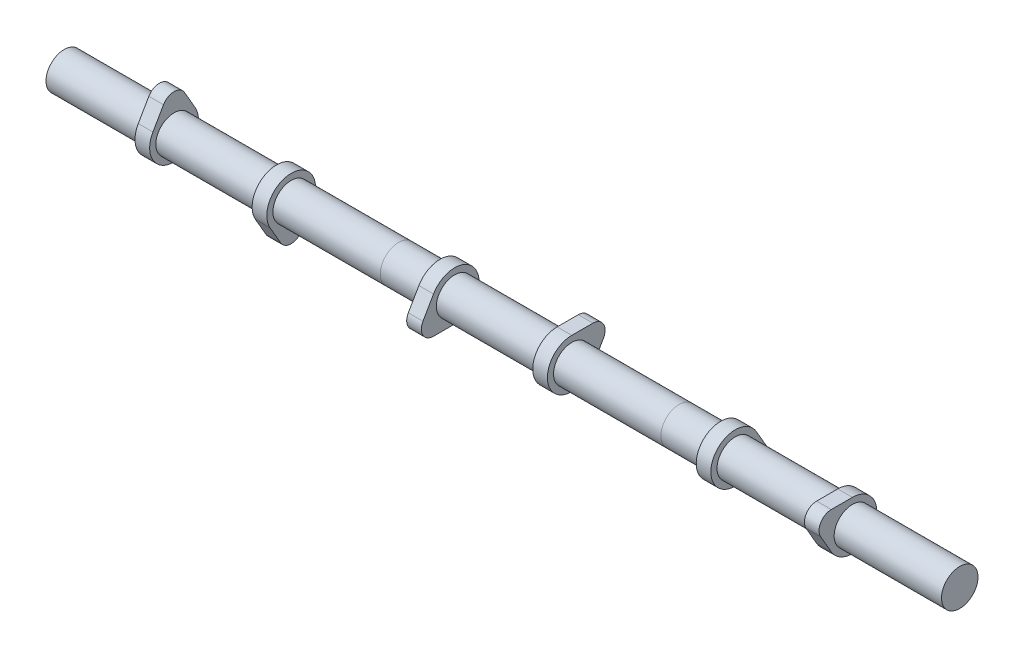
from build123d import *

# Parameters (mm, degrees)
BOSS_EXTRUDE1_DEPTH   = 3.81
BODY_MOVE_COPY2_ANGLE = 180
BOSS_EXTRUDE2_START   = -25.4
SKETCH3_R             = 9.5
BOSS_EXTRUDE2_DEPTH   = 146.05
LPATTERN1_COUNT       = 3
LPATTERN1_PITCH       = 146.05
BODY_MOVE_COPY3_ANGLE = 120
BODY_MOVE_COPY4_ANGLE = 120
BOSS_EXTRUDE3_START   = 27.94
SKETCH4_R             = 9.5
BOSS_EXTRUDE3_DEPTH   = 27.94


with BuildPart() as part:
    # Sketch2 → Boss-Extrude1 (new, symmetric)
    with BuildSketch(Plane(origin=(0, 0, 0), x_dir=(0, 0, -1), z_dir=(1, 0, 0))):
        with BuildLine():
            Line((-5.499261314, 15.875), (-10.998522628, 6.35))
            ThreePointArc((-10.998522628, 6.35), (0, -12.7), (10.998522628, 6.35))
            Line((10.998522628, 6.35), (5.499261314, 15.875))
            ThreePointArc((5.499261314, 15.875), (0, 19.05), (-5.499261314, 15.875))
        make_face()
    extrude(amount=BOSS_EXTRUDE1_DEPTH, both=True)


with BuildPart() as body_2:
    # Body-Move_Copy1: copy of part
    add(part.part.moved(Location((60.96, 0, 0))))


with BuildPart() as body_2_1:
    # Body-Move_Copy2: moved
    add(body_2.part.rotate(Axis((0, 0, 0), (1, 0, 0)), BODY_MOVE_COPY2_ANGLE))


with BuildPart() as part_1:
    add(part.part)

    add(body_2_1.part)  # Boss-Extrude2 merges body 2
    # Sketch3 → Boss-Extrude2 (add)
    with BuildSketch(Plane(origin=(0, 0, 0), x_dir=(0, 0, -1), z_dir=(1, 0, 0)).offset(BOSS_EXTRUDE2_START)):
        Circle(SKETCH3_R)
    extrude(amount=BOSS_EXTRUDE2_DEPTH)


with BuildPart() as lpattern1_1:
    # LPattern1: pattern copy
    add(part_1.part.moved(Location(Vector(1, 0, 0) * (1 * LPATTERN1_PITCH))))


with BuildPart() as lpattern1_2:
    # LPattern1: pattern copy
    add(part_1.part.moved(Location(Vector(1, 0, 0) * (2 * LPATTERN1_PITCH))))


with BuildPart() as lpattern1_1_1:
    # Body-Move_Copy3: moved
    add(lpattern1_1.part.rotate(Axis((0, 0, 0), (1, 0, 0)), BODY_MOVE_COPY3_ANGLE))


with BuildPart() as lpattern1_2_1:
    # Body-Move_Copy4: moved
    add(lpattern1_2.part.rotate(Axis((0, 0, 0), (-1, 0, 0)), BODY_MOVE_COPY4_ANGLE))


with BuildPart() as part_2:
    add(part_1.part)

    # Sketch4 → Boss-Extrude3 (add)
    with BuildSketch(Plane.ZY.offset(25.4).offset(BOSS_EXTRUDE3_START)):
        Circle(SKETCH4_R)
    extrude(amount=-BOSS_EXTRUDE3_DEPTH)


solid = Compound([lpattern1_1_1.part, lpattern1_2_1.part, part_2.part])
